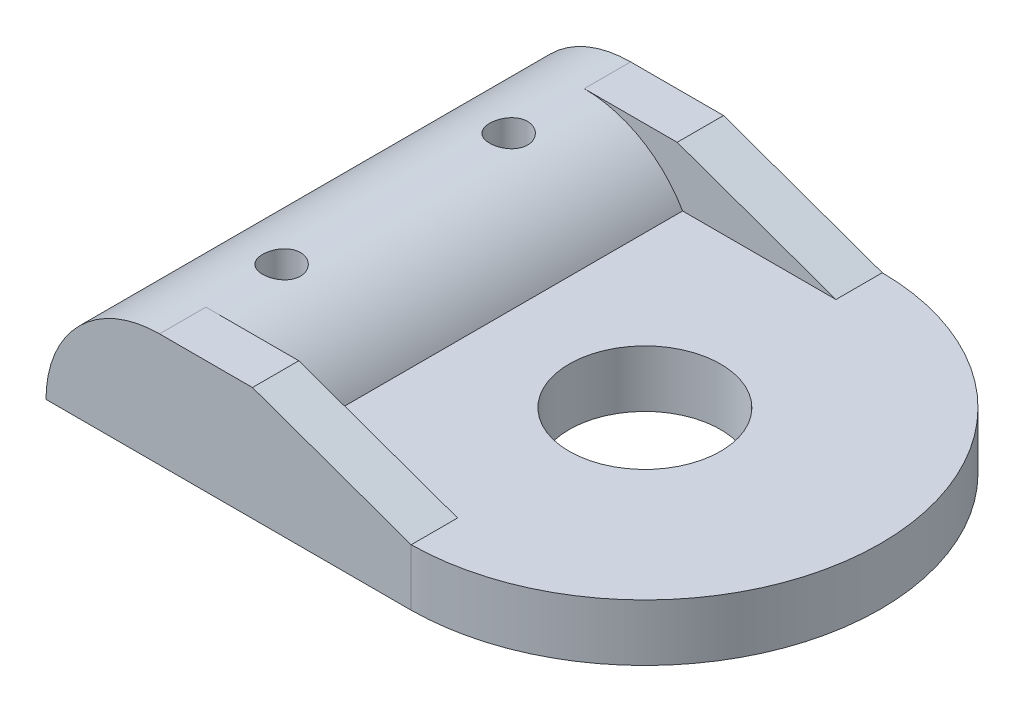
from build123d import *

# Parameters (mm, degrees)
CROQUIS1_R              = 3.999426158
CROQUIS1_R_2            = 1.000000121
CROQUIS1_R_3            = 1.000000477
SALIENTE_EXTRUIR1_DEPTH = 3
SALIENTE_EXTRUIR2_DEPTH = 24.89496
CROQUIS3_W              = 13.299999714
CROQUIS3_H              = 2.45
SALIENTE_EXTRUIR3_DEPTH = 3
CORTAR_EXTRUIR1_DEPTH   = 24.89496
CROQUIS5_R              = 1.000000121
CROQUIS5_R_2            = 1.000000477
CORTAR_EXTRUIR2_DEPTH   = 11


with BuildPart() as part:
    # Croquis1 → Saliente-Extruir1 (new body)
    with BuildSketch(Plane(origin=(0, 0, 0), x_dir=(1, 0, 0), z_dir=(0, 1, 0))):
        with BuildLine():
            Line((4.218422555, -12.81969876), (-15.081577159, -12.81969876))
            Line((-15.081577159, -12.81969876), (-15.081577159, 12.075260967))
            Line((-15.081577159, 12.075260967), (4.218422555, 12.075260967))
            ThreePointArc((4.218422555, 12.075260967), (16.567050884, -0.372218896), (4.218422555, -12.81969876))
        make_face()
        with Locations((4.119175364, -0.372218896)):
            Circle(CROQUIS1_R, mode=Mode.SUBTRACT)
        with Locations((-9.081577367, 5.628403394)):
            Circle(CROQUIS1_R_2, mode=Mode.SUBTRACT)
        with Locations((-9.081576585, -6.371596672)):
            Circle(CROQUIS1_R_3, mode=Mode.SUBTRACT)
    extrude(amount=SALIENTE_EXTRUIR1_DEPTH)

    # Croquis2 → Saliente-Extruir2 (add)
    with BuildSketch(Plane.XY.offset(12.81969876)):
        with BuildLine():
            Line((-14.277729582, 3), (-3.885424736, 3))
            ThreePointArc((-3.885424736, 3), (-9.081577159, 6), (-14.277729582, 3))
        make_face()
    extrude(amount=-SALIENTE_EXTRUIR2_DEPTH)

    # Croquis3 → Saliente-Extruir3 (add)
    with BuildSketch(Plane(origin=(0, 3, 0), x_dir=(1, 0, 0), z_dir=(0, 1, 0))):
        with Locations((-2.431577302, -11.59469876)):
            Rectangle(CROQUIS3_W, CROQUIS3_H)
        with Locations((-2.431577302, 10.850260967)):
            Rectangle(CROQUIS3_W, CROQUIS3_H)
    extrude(amount=SALIENTE_EXTRUIR3_DEPTH)

    # Croquis4 → Cortar-Extruir1 (cut)
    with BuildSketch(Plane.XY.offset(12.81969876)):
        Polygon((-4.171577445, 6), (4.218422555, 3), (4.218422555, 6), align=None)
        with BuildLine():
            Line((-15.081577159, 0), (-16.256016644, 0))
            ThreePointArc((-16.256016644, 0), (-14.36312843, 4.855697487), (-9.683294652, 7.149162047))
            Line((-9.683294652, 7.149162047), (-9.683294652, 5.969751759))
            ThreePointArc((-9.683294652, 5.969751759), (-13.53187518, 4.024282237), (-15.081577159, 0))
        make_face()
    extrude(amount=-CORTAR_EXTRUIR1_DEPTH, mode=Mode.SUBTRACT)

    # Croquis5 → Cortar-Extruir2 (cut)
    with BuildSketch(Plane.XZ):
        with Locations((-9.081577367, -5.628403394)):
            Circle(CROQUIS5_R)
        with Locations((-9.081576585, 6.371596672)):
            Circle(CROQUIS5_R_2)
    extrude(amount=-CORTAR_EXTRUIR2_DEPTH, mode=Mode.SUBTRACT)


solid = part.part
